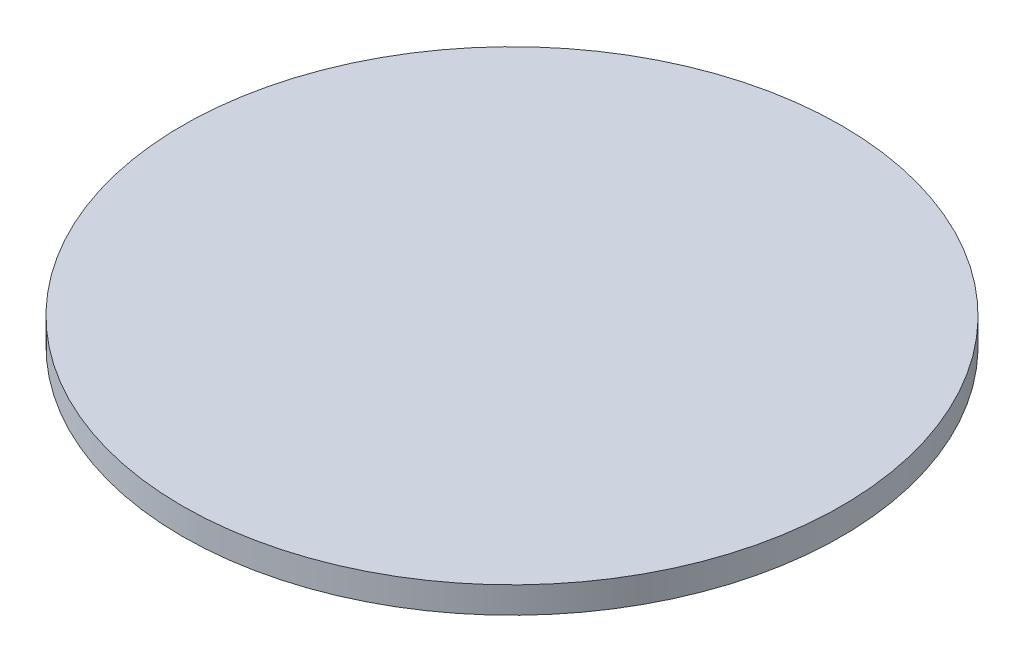
from build123d import *

# Parameters (mm, degrees)
SKETCH_1_R      = 25
EXTRUDE_1_DEPTH = 2


with BuildPart() as part:
    # 草圖1 → 填料-伸長1 (new body)
    with BuildSketch(Plane(origin=(0, 0, 0), x_dir=(1, 0, 0), z_dir=(0, 1, 0))):
        with Locations((-1.57120846, 0)):
            Circle(SKETCH_1_R)
    extrude(amount=EXTRUDE_1_DEPTH)


solid = part.part
